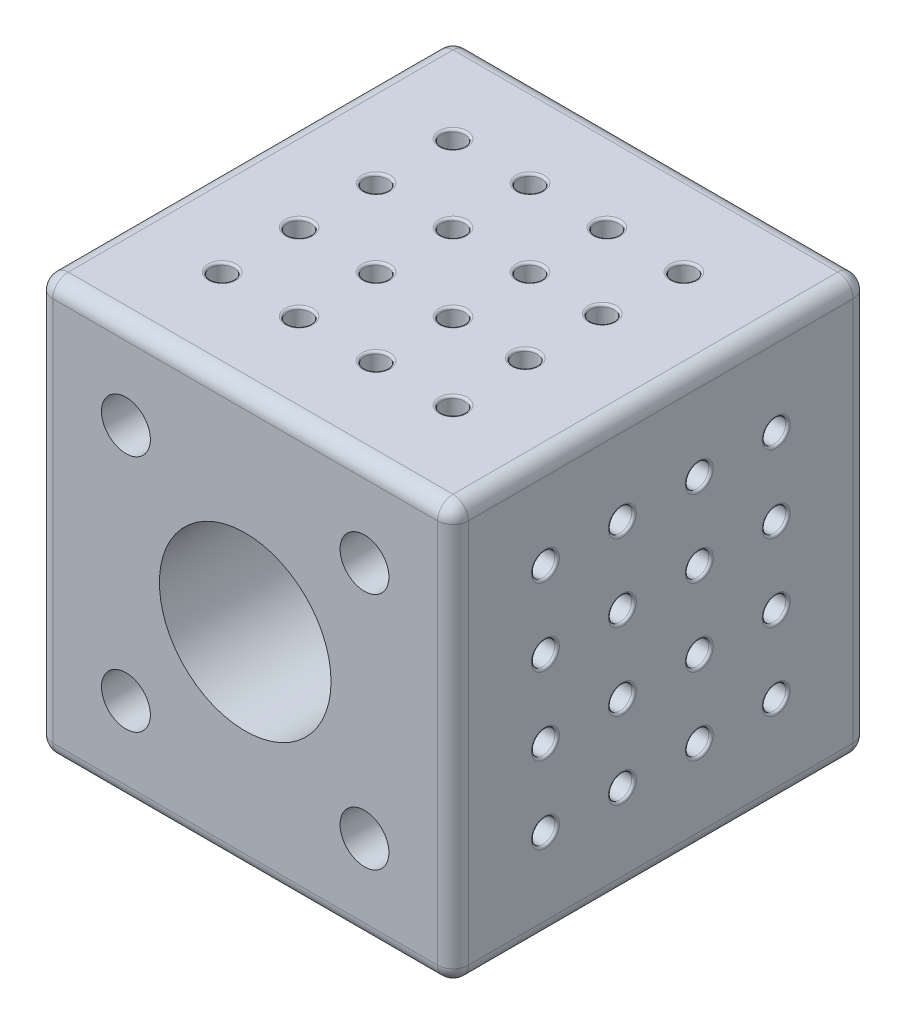
from build123d import *

# Parameters (mm, degrees)
SKETCH2_W                = 54
SKETCH2_H                = 54
BOSS_EXTRUDE1_DEPTH      = 54
BOSS_EXTRUDE1_DEPTH_BACK = 0.0001
FILLET1_R                = 2
FILLET2_R                = 2
SKETCH4_R                = 11.15
CUT_EXTRUDE1_DEPTH       = 17
SKETCH12_R               = 6.2
CUT_EXTRUDE2_DEPTH       = 33.5
SKETCH13_R               = 3.175
CUT_EXTRUDE3_DEPTH       = 21.5001
SKETCH15_R               = 1.5
CUT_EXTRUDE4_DEPTH       = 38.0001
SKETCH16_R               = 6.075
CUT_EXTRUDE5_DEPTH       = 38.0001
SKETCH17_R               = 11.15
CUT_EXTRUDE6_DEPTH       = 18
SKETCH18_R               = 11.1
CUT_EXTRUDE7_DEPTH       = 1
SKETCH19_R               = 1.525
CUT_EXTRUDE8_DEPTH       = 4
SKETCH21_R               = 1.525
CUT_EXTRUDE10_DEPTH      = 4
SKETCH22_R               = 1.525
CUT_EXTRUDE11_DEPTH      = 4
SKETCH25_R               = 1.525
CUT_EXTRUDE13_DEPTH      = 4
FILLET3_R                = 0.3
FILLET4_R                = 0.3
FILLET5_R                = 0.3
FILLET6_R                = 0.3


with BuildPart() as part:
    # Sketch2 → Boss-Extrude1 (new body, two sides)
    with BuildSketch(Plane.XY) as boss_extrude1_sk:
        with Locations((5.224836601, 7.517647059)):
            Rectangle(SKETCH2_W, SKETCH2_H)
    extrude(amount=BOSS_EXTRUDE1_DEPTH)
    extrude(boss_extrude1_sk.sketch, amount=-BOSS_EXTRUDE1_DEPTH_BACK)

    # Fillet1
    fillet1_edges = [part.edges().sort_by_distance(p)[0] for p in [
        (-21.775163399, 34.517647059, 26.99995),
        (32.224836601, 34.517647059, 26.99995),
        (32.224836601, -19.482352941, 26.99995),
        (-21.775163399, -19.482352941, 26.99995),
    ]]
    fillet(fillet1_edges, radius=FILLET1_R)

    # Fillet2
    fillet2_edges = [part.edges().sort_by_distance(p)[0] for p in [
        (-21.775163399, 7.517647059, 54),
        (-21.775163399, 7.517647059, -0.0001),
        (5.224836601, -19.482352941, 54),
        (32.224836601, 7.517647059, 54),
        (5.224836601, 34.517647059, 54),
        (31.639050164, 33.931860621, 54),
        (31.639050164, -18.896566504, 54),
        (-21.189376961, 33.931860621, 54),
        (-21.189376961, -18.896566504, 54),
        (5.224836601, -19.482352941, -0.0001),
        (5.224836601, 34.517647059, -0.0001),
        (32.224836601, 7.517647059, -0.0001),
        (31.639050164, 33.931860621, -0.0001),
        (31.639050164, -18.896566504, -0.0001),
        (-21.189376961, 33.931860621, -0.0001),
        (-21.189376961, -18.896566504, -0.0001),
    ]]
    fillet(fillet2_edges, radius=FILLET2_R)

    # Sketch4 → Cut-Extrude1 (cut)
    with BuildSketch(Plane(origin=(0, 0, -0.0001), x_dir=(-1, 0, 0), z_dir=(0, 0, -1))):
        with Locations((-5.224836601, 7.517647059)):
            Circle(SKETCH4_R)
    extrude(amount=-CUT_EXTRUDE1_DEPTH, mode=Mode.SUBTRACT)

    # Sketch12 → Cut-Extrude2 (cut)
    with BuildSketch(Plane(origin=(0, 0, -0.0001), x_dir=(-1, 0, 0), z_dir=(0, 0, -1))):
        with Locations((-20.724836601, 23.017647059)):
            Circle(SKETCH12_R)
        with Locations((10.275163399, 23.017647059)):
            Circle(SKETCH12_R)
        with Locations((-20.724836601, -7.982352941)):
            Circle(SKETCH12_R)
        with Locations((10.275163399, -7.982352941)):
            Circle(SKETCH12_R)
    extrude(amount=-CUT_EXTRUDE2_DEPTH, mode=Mode.SUBTRACT)

    # Sketch13 → Cut-Extrude3 (cut, through all)
    with BuildSketch(Plane(origin=(0, 0, 33.4999), x_dir=(-1, 0, 0), z_dir=(0, 0, -1))):
        with Locations((-20.724836601, 23.017647059)):
            Circle(SKETCH13_R)
        with Locations((10.275163399, 23.017647059)):
            Circle(SKETCH13_R)
        with Locations((10.275163399, -7.982352941)):
            Circle(SKETCH13_R)
        with Locations((-20.724836601, -7.982352941)):
            Circle(SKETCH13_R)
    extrude(amount=-CUT_EXTRUDE3_DEPTH, mode=Mode.SUBTRACT)

    # Sketch15 → Cut-Extrude4 (cut, through all)
    with BuildSketch(Plane(origin=(0, 0, 16.9999), x_dir=(-1, 0, 0), z_dir=(0, 0, -1))):
        with Locations((-5.224836601, 15.367647059)):
            Circle(SKETCH15_R)
        with Locations((-13.374836601, 7.517647059)):
            Circle(SKETCH15_R)
        with Locations((-5.224836601, -0.632352941)):
            Circle(SKETCH15_R)
        with Locations((2.625163399, 7.517647059)):
            Circle(SKETCH15_R)
    extrude(amount=-CUT_EXTRUDE4_DEPTH, mode=Mode.SUBTRACT)

    # Sketch16 → Cut-Extrude5 (cut, through all)
    with BuildSketch(Plane(origin=(0, 0, 16.9999), x_dir=(-1, 0, 0), z_dir=(0, 0, -1))):
        with Locations((-5.224836601, 7.517647059)):
            Circle(SKETCH16_R)
    extrude(amount=-CUT_EXTRUDE5_DEPTH, mode=Mode.SUBTRACT)

    # Sketch17 → Cut-Extrude6 (cut)
    with BuildSketch(Plane.XY.offset(54)):
        with Locations((5.224836601, 7.517647059)):
            Circle(SKETCH17_R)
    extrude(amount=-CUT_EXTRUDE6_DEPTH, mode=Mode.SUBTRACT)

    # Sketch18 → Cut-Extrude7 (cut)
    with BuildSketch(Plane(origin=(0, 0, 16.9999), x_dir=(-1, 0, 0), z_dir=(0, 0, -1))):
        with Locations((-5.224836601, 7.517647059)):
            Circle(SKETCH18_R)
    extrude(amount=-CUT_EXTRUDE7_DEPTH, mode=Mode.SUBTRACT)

    # Sketch19 → Cut-Extrude8 (cut)
    with BuildSketch(Plane(origin=(0, 34.517647059, 0), x_dir=(1, 0, 0), z_dir=(0, 1, 0))):
        with Locations((-9.775163399, -11.9999)):
            Circle(SKETCH19_R)
        with Locations((0.224836601, -11.9999)):
            Circle(SKETCH19_R)
        with Locations((10.224836601, -11.9999)):
            Circle(SKETCH19_R)
        with Locations((20.224836601, -11.9999)):
            Circle(SKETCH19_R)
        with Locations((-9.775163399, -21.9999)):
            Circle(SKETCH19_R)
        with Locations((0.224836601, -21.9999)):
            Circle(SKETCH19_R)
        with Locations((10.224836601, -21.9999)):
            Circle(SKETCH19_R)
        with Locations((19.610044829, -21.9999)):
            Circle(SKETCH19_R)
        with Locations((-9.775163399, -31.9999)):
            Circle(SKETCH19_R)
        with Locations((0.224836601, -31.9999)):
            Circle(SKETCH19_R)
        with Locations((10.224836601, -31.9999)):
            Circle(SKETCH19_R)
        with Locations((19.610044829, -31.9999)):
            Circle(SKETCH19_R)
        with Locations((-9.775163399, -41.9999)):
            Circle(SKETCH19_R)
        with Locations((0.224836601, -41.9999)):
            Circle(SKETCH19_R)
        with Locations((10.224836601, -42)):
            Circle(SKETCH19_R)
        with Locations((20.224836601, -42)):
            Circle(SKETCH19_R)
    extrude(amount=-CUT_EXTRUDE8_DEPTH, mode=Mode.SUBTRACT)

    # Sketch21 → Cut-Extrude10 (cut)
    with BuildSketch(Plane(origin=(32.224836601, 0, 0), x_dir=(0, -1, 0), z_dir=(1, 0, 0))):
        with Locations((-22.517647059, -12)):
            Circle(SKETCH21_R)
        with Locations((-12.517647059, -12)):
            Circle(SKETCH21_R)
        with Locations((-2.517647059, -12)):
            Circle(SKETCH21_R)
        with Locations((7.482352941, -12)):
            Circle(SKETCH21_R)
        with Locations((-22.517647059, -22)):
            Circle(SKETCH21_R)
        with Locations((-12.517647059, -22)):
            Circle(SKETCH21_R)
        with Locations((-2.517647059, -22)):
            Circle(SKETCH21_R)
        with Locations((7.482352941, -22)):
            Circle(SKETCH21_R)
        with Locations((-22.517647059, -32)):
            Circle(SKETCH21_R)
        with Locations((-12.517647059, -32)):
            Circle(SKETCH21_R)
        with Locations((-2.517647059, -32)):
            Circle(SKETCH21_R)
        with Locations((7.482352941, -32)):
            Circle(SKETCH21_R)
        with Locations((-22.517647059, -42)):
            Circle(SKETCH21_R)
        with Locations((-12.517647059, -42)):
            Circle(SKETCH21_R)
        with Locations((-2.517647059, -42)):
            Circle(SKETCH21_R)
        with Locations((7.482352941, -42)):
            Circle(SKETCH21_R)
    extrude(amount=-CUT_EXTRUDE10_DEPTH, mode=Mode.SUBTRACT)

    # Sketch22 → Cut-Extrude11 (cut)
    with BuildSketch(Plane(origin=(0, -19.482352941, 0), x_dir=(0, 0, 1), z_dir=(0, -1, 0))):
        with Locations((11.9999, 9.775163399)):
            Circle(SKETCH22_R)
        with Locations((21.9999, 9.775163399)):
            Circle(SKETCH22_R)
        with Locations((31.9999, 9.775163399)):
            Circle(SKETCH22_R)
        with Locations((41.9999, 9.775163399)):
            Circle(SKETCH22_R)
        with Locations((11.9999, -0.224836601)):
            Circle(SKETCH22_R)
        with Locations((21.9999, -0.224836601)):
            Circle(SKETCH22_R)
        with Locations((31.9999, -0.224836601)):
            Circle(SKETCH22_R)
        with Locations((41.9999, -0.224836601)):
            Circle(SKETCH22_R)
        with Locations((11.9999, -10.224836601)):
            Circle(SKETCH22_R)
        with Locations((21.9999, -10.224836601)):
            Circle(SKETCH22_R)
        with Locations((31.9999, -10.224836601)):
            Circle(SKETCH22_R)
        with Locations((41.9999, -10.224836601)):
            Circle(SKETCH22_R)
        with Locations((11.9999, -20.224836601)):
            Circle(SKETCH22_R)
        with Locations((21.9999, -20.224836601)):
            Circle(SKETCH22_R)
        with Locations((31.9999, -20.224836601)):
            Circle(SKETCH22_R)
        with Locations((41.9999, -20.224836601)):
            Circle(SKETCH22_R)
    extrude(amount=-CUT_EXTRUDE11_DEPTH, mode=Mode.SUBTRACT)

    # Sketch25 → Cut-Extrude13 (cut)
    with BuildSketch(Plane.ZY.offset(21.775163399)):
        with Locations((11.9999, 22.517647059)):
            Circle(SKETCH25_R)
        with Locations((21.9999, 22.517647059)):
            Circle(SKETCH25_R)
        with Locations((31.9999, 22.517647059)):
            Circle(SKETCH25_R)
        with Locations((41.9999, 22.517647059)):
            Circle(SKETCH25_R)
        with Locations((11.9999, 12.517647059)):
            Circle(SKETCH25_R)
        with Locations((21.9999, 12.517647059)):
            Circle(SKETCH25_R)
        with Locations((31.9999, 12.517647059)):
            Circle(SKETCH25_R)
        with Locations((41.9999, 12.517647059)):
            Circle(SKETCH25_R)
        with Locations((11.9999, 2.517647059)):
            Circle(SKETCH25_R)
        with Locations((21.9999, 2.517647059)):
            Circle(SKETCH25_R)
        with Locations((31.9999, 2.517647059)):
            Circle(SKETCH25_R)
        with Locations((41.9999, 2.517647059)):
            Circle(SKETCH25_R)
        with Locations((11.9999, -7.482352941)):
            Circle(SKETCH25_R)
        with Locations((21.9999, -7.482352941)):
            Circle(SKETCH25_R)
        with Locations((31.9999, -7.482352941)):
            Circle(SKETCH25_R)
        with Locations((41.9999, -7.482352941)):
            Circle(SKETCH25_R)
    extrude(amount=-CUT_EXTRUDE13_DEPTH, mode=Mode.SUBTRACT)

    # Fillet3
    fillet3_edges = [part.edges().sort_by_distance(p)[0] for p in [
        (-17.775163399, 12.517647059, 10.4749),
        (-21.775163399, 12.517647059, 10.4749),
        (-17.775163399, 12.517647059, 30.4749),
        (-21.775163399, 12.517647059, 30.4749),
        (-17.775163399, 12.517647059, 40.4749),
        (-21.775163399, 12.517647059, 40.4749),
        (-17.775163399, 2.517647059, 10.4749),
        (-21.775163399, 2.517647059, 10.4749),
        (-17.775163399, 22.517647059, 20.4749),
        (-21.775163399, 22.517647059, 20.4749),
        (-17.775163399, 22.517647059, 30.4749),
        (-21.775163399, 22.517647059, 30.4749),
        (-17.775163399, 22.517647059, 40.4749),
        (-21.775163399, 22.517647059, 40.4749),
        (-17.775163399, 12.517647059, 20.4749),
        (-21.775163399, 12.517647059, 20.4749),
        (-17.775163399, -7.482352941, 40.4749),
        (-21.775163399, -7.482352941, 40.4749),
        (-17.775163399, -7.482352941, 30.4749),
        (-21.775163399, -7.482352941, 30.4749),
        (-17.775163399, -7.482352941, 20.4749),
        (-21.775163399, -7.482352941, 20.4749),
        (-17.775163399, 2.517647059, 20.4749),
        (-21.775163399, 2.517647059, 20.4749),
        (-17.775163399, 2.517647059, 30.4749),
        (-21.775163399, 2.517647059, 30.4749),
        (-17.775163399, 2.517647059, 40.4749),
        (-21.775163399, 2.517647059, 40.4749),
        (-17.775163399, -7.482352941, 10.4749),
        (-21.775163399, -7.482352941, 10.4749),
        (-17.775163399, 22.517647059, 10.4749),
        (-21.775163399, 22.517647059, 10.4749),
    ]]
    fillet(fillet3_edges, radius=FILLET3_R)

    # Fillet4
    fillet4_edges = [part.edges().sort_by_distance(p)[0] for p in [
        (0.224836601, -15.482352941, 10.4749),
        (0.224836601, -19.482352941, 10.4749),
        (0.224836601, -15.482352941, 30.4749),
        (0.224836601, -19.482352941, 30.4749),
        (0.224836601, -15.482352941, 40.4749),
        (0.224836601, -19.482352941, 40.4749),
        (10.224836601, -15.482352941, 10.4749),
        (10.224836601, -19.482352941, 10.4749),
        (-9.775163399, -15.482352941, 20.4749),
        (-9.775163399, -19.482352941, 20.4749),
        (-9.775163399, -15.482352941, 30.4749),
        (-9.775163399, -19.482352941, 30.4749),
        (-9.775163399, -15.482352941, 40.4749),
        (-9.775163399, -19.482352941, 40.4749),
        (0.224836601, -15.482352941, 20.4749),
        (0.224836601, -19.482352941, 20.4749),
        (20.224836601, -15.482352941, 40.4749),
        (20.224836601, -19.482352941, 40.4749),
        (20.224836601, -15.482352941, 30.4749),
        (20.224836601, -19.482352941, 30.4749),
        (20.224836601, -15.482352941, 20.4749),
        (20.224836601, -19.482352941, 20.4749),
        (10.224836601, -15.482352941, 20.4749),
        (10.224836601, -19.482352941, 20.4749),
        (10.224836601, -15.482352941, 30.4749),
        (10.224836601, -19.482352941, 30.4749),
        (10.224836601, -15.482352941, 40.4749),
        (10.224836601, -19.482352941, 40.4749),
        (20.224836601, -15.482352941, 10.4749),
        (20.224836601, -19.482352941, 10.4749),
        (-9.775163399, -15.482352941, 10.4749),
        (-9.775163399, -19.482352941, 10.4749),
    ]]
    fillet(fillet4_edges, radius=FILLET4_R)

    # Fillet5
    fillet5_edges = [part.edges().sort_by_distance(p)[0] for p in [
        (28.224836601, 24.042647059, 22),
        (32.224836601, 24.042647059, 22),
        (28.224836601, 4.042647059, 22),
        (32.224836601, 4.042647059, 22),
        (28.224836601, -5.957352941, 22),
        (32.224836601, -5.957352941, 22),
        (28.224836601, 24.042647059, 32),
        (32.224836601, 24.042647059, 32),
        (28.224836601, 14.042647059, 12),
        (32.224836601, 14.042647059, 12),
        (28.224836601, 4.042647059, 12),
        (32.224836601, 4.042647059, 12),
        (28.224836601, -5.957352941, 12),
        (32.224836601, -5.957352941, 12),
        (28.224836601, 14.042647059, 22),
        (32.224836601, 14.042647059, 22),
        (28.224836601, -5.957352941, 42),
        (32.224836601, -5.957352941, 42),
        (28.224836601, 4.042647059, 42),
        (32.224836601, 4.042647059, 42),
        (28.224836601, 14.042647059, 42),
        (32.224836601, 14.042647059, 42),
        (28.224836601, 14.042647059, 32),
        (32.224836601, 14.042647059, 32),
        (28.224836601, 4.042647059, 32),
        (32.224836601, 4.042647059, 32),
        (28.224836601, -5.957352941, 32),
        (32.224836601, -5.957352941, 32),
        (28.224836601, 24.042647059, 42),
        (32.224836601, 24.042647059, 42),
        (28.224836601, 24.042647059, 12),
        (32.224836601, 24.042647059, 12),
    ]]
    fillet(fillet5_edges, radius=FILLET5_R)

    # Fillet6
    fillet6_edges = [part.edges().sort_by_distance(p)[0] for p in [
        (-11.300163399, 30.517647059, 21.9999),
        (-11.300163399, 34.517647059, 21.9999),
        (8.699836601, 30.517647059, 21.9999),
        (8.699836601, 34.517647059, 21.9999),
        (18.085044829, 30.517647059, 21.9999),
        (18.085044829, 34.517647059, 21.9999),
        (-11.300163399, 30.517647059, 31.9999),
        (-11.300163399, 34.517647059, 31.9999),
        (-1.300163399, 30.517647059, 11.9999),
        (-1.300163399, 34.517647059, 11.9999),
        (8.699836601, 30.517647059, 11.9999),
        (8.699836601, 34.517647059, 11.9999),
        (18.699836601, 30.517647059, 11.9999),
        (18.699836601, 34.517647059, 11.9999),
        (-1.300163399, 30.517647059, 21.9999),
        (-1.300163399, 34.517647059, 21.9999),
        (18.699836601, 30.517647059, 42),
        (18.699836601, 34.517647059, 42),
        (8.699836601, 30.517647059, 42),
        (8.699836601, 34.517647059, 42),
        (-1.300163399, 30.517647059, 41.9999),
        (-1.300163399, 34.517647059, 41.9999),
        (-1.300163399, 30.517647059, 31.9999),
        (-1.300163399, 34.517647059, 31.9999),
        (8.699836601, 30.517647059, 31.9999),
        (8.699836601, 34.517647059, 31.9999),
        (18.085044829, 30.517647059, 31.9999),
        (18.085044829, 34.517647059, 31.9999),
        (-11.300163399, 30.517647059, 41.9999),
        (-11.300163399, 34.517647059, 41.9999),
        (-11.300163399, 30.517647059, 11.9999),
        (-11.300163399, 34.517647059, 11.9999),
    ]]
    fillet(fillet6_edges, radius=FILLET6_R)


solid = part.part
